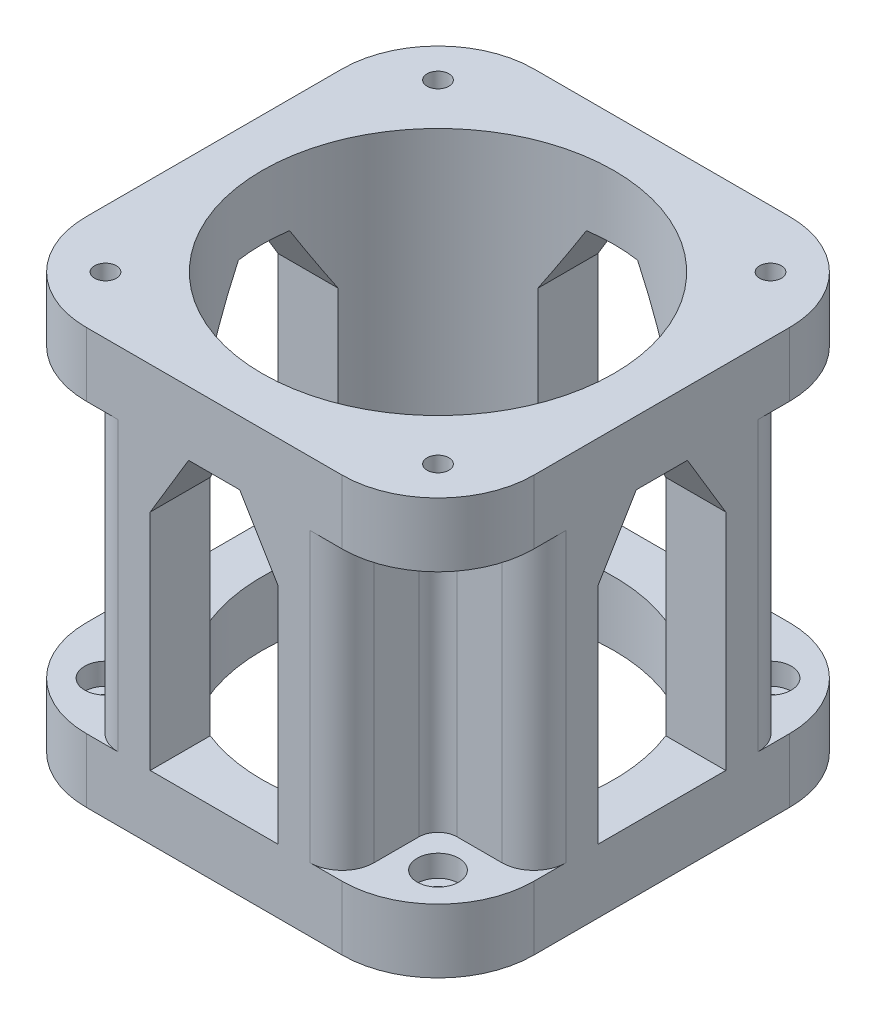
from build123d import *

# Parameters (mm, degrees)
SKETCH1_W                                           = 70
SKETCH1_H                                           = 70
BOSS_EXTRUDE1_DEPTH                                 = 65
FILLET1_R                                           = 15
SKETCH2_R                                           = 27.5
CUT_EXTRUDE1_DEPTH                                  = 65
CUT_EXTRUDE2_DEPTH                                  = 71
CUT_EXTRUDE3_DEPTH                                  = 71
CUT_EXTRUDE4_START                                  = -10
SKETCH10_W                                          = 15
SKETCH10_H                                          = 15
CUT_EXTRUDE4_DEPTH                                  = 45
CBORE_FOR_M3_HEX_SOCKET_HEAD_CAP_SCREW1_D           = 3.4
CBORE_FOR_M3_HEX_SOCKET_HEAD_CAP_SCREW1_DEPTH       = 10
CBORE_FOR_M3_HEX_SOCKET_HEAD_CAP_SCREW1_CBORE_D     = 6.5
CBORE_FOR_M3_HEX_SOCKET_HEAD_CAP_SCREW1_CBORE_DEPTH = 3.4
FILLET2_R                                           = 3
CBORE_FOR_M3_HEX_SOCKET_HEAD_CAP_SCREW2_D           = 3.4
CBORE_FOR_M3_HEX_SOCKET_HEAD_CAP_SCREW2_DEPTH       = 10
CBORE_FOR_M3_HEX_SOCKET_HEAD_CAP_SCREW2_CBORE_D     = 6.5
CBORE_FOR_M3_HEX_SOCKET_HEAD_CAP_SCREW2_CBORE_DEPTH = 3.4
FILLET3_R                                           = 5


with BuildPart() as part:
    # Sketch1 → Boss-Extrude1 (new body)
    with BuildSketch(Plane(origin=(0, 0, 0), x_dir=(1, 0, 0), z_dir=(0, 1, 0))):
        Rectangle(SKETCH1_W, SKETCH1_H)
    extrude(amount=BOSS_EXTRUDE1_DEPTH)

    # Fillet1
    fillet1_edges = [part.edges().sort_by_distance(p)[0] for p in [
        (-35, 32.5, -35),
        (35, 32.5, -35),
        (35, 32.5, 35),
        (-35, 32.5, 35),
    ]]
    fillet(fillet1_edges, radius=FILLET1_R)

    # Sketch2 → Cut-Extrude1 (cut)
    with BuildSketch(Plane(origin=(0, 65, 0), x_dir=(1, 0, 0), z_dir=(0, 1, 0))):
        Circle(SKETCH2_R)
    extrude(amount=-CUT_EXTRUDE1_DEPTH, mode=Mode.SUBTRACT)

    # Sketch3 → Cut-Extrude2 (cut, through all)
    with BuildSketch(Plane(origin=(0, 0, -35), x_dir=(-1, 0, 0), z_dir=(0, 0, -1))):
        Polygon((-10, 10), (-10, 45), (-4, 55), (4, 55), (10, 45), (10, 10), align=None)
    extrude(amount=-CUT_EXTRUDE2_DEPTH, mode=Mode.SUBTRACT)

    # Sketch4 → Cut-Extrude3 (cut, through all)
    with BuildSketch(Plane(origin=(35, 0, 0), x_dir=(0, 0, -1), z_dir=(1, 0, 0))):
        Polygon((-10, 10), (-10, 45), (-4, 55), (4, 55), (10, 45), (10, 10), align=None)
    extrude(amount=-CUT_EXTRUDE3_DEPTH, mode=Mode.SUBTRACT)

    # Sketch10 → Cut-Extrude4 (cut)
    with BuildSketch(Plane(origin=(0, 65, 0), x_dir=(1, 0, 0), z_dir=(0, 1, 0)).offset(CUT_EXTRUDE4_START)):
        with Locations((-27.5, 27.5)):
            Rectangle(SKETCH10_W, SKETCH10_H)
        with Locations((-27.5, -27.5)):
            Rectangle(SKETCH10_W, SKETCH10_H)
        with Locations((27.5, -27.5)):
            Rectangle(SKETCH10_W, SKETCH10_H)
        with Locations((27.5, 27.5)):
            Rectangle(SKETCH10_W, SKETCH10_H)
    extrude(amount=-CUT_EXTRUDE4_DEPTH, mode=Mode.SUBTRACT)

    # CBORE for M3 Hex Socket Head Cap Screw1
    with Locations(Plane(origin=(0, 55, 0), x_dir=(-1, 0, 0), z_dir=(0, -1, 0))):
        with Locations((26, -26), (-26, -26), (-26, 26), (26, 26)):
            CounterBoreHole(CBORE_FOR_M3_HEX_SOCKET_HEAD_CAP_SCREW1_D / 2, CBORE_FOR_M3_HEX_SOCKET_HEAD_CAP_SCREW1_CBORE_D / 2, CBORE_FOR_M3_HEX_SOCKET_HEAD_CAP_SCREW1_CBORE_DEPTH, depth=CBORE_FOR_M3_HEX_SOCKET_HEAD_CAP_SCREW1_DEPTH)

    # Fillet2
    fillet2_edges = [part.edges().sort_by_distance(p)[0] for p in [
        (20, 32.5, -20),
        (20, 32.5, 20),
        (-20, 32.5, 20),
        (-20, 32.5, -20),
    ]]
    fillet(fillet2_edges, radius=FILLET2_R)

    # CBORE for M3 Hex Socket Head Cap Screw2
    with Locations(Plane(origin=(0, 10, 0), x_dir=(1, 0, 0), z_dir=(0, 1, 0))):
        with Locations((26, -26), (26, 26), (-26, 26), (-26, -26)):
            CounterBoreHole(CBORE_FOR_M3_HEX_SOCKET_HEAD_CAP_SCREW2_D / 2, CBORE_FOR_M3_HEX_SOCKET_HEAD_CAP_SCREW2_CBORE_D / 2, CBORE_FOR_M3_HEX_SOCKET_HEAD_CAP_SCREW2_CBORE_DEPTH, depth=CBORE_FOR_M3_HEX_SOCKET_HEAD_CAP_SCREW2_DEPTH)

    # Fillet3
    fillet3_edges = [part.edges().sort_by_distance(p)[0] for p in [
        (35, 32.5, -20),
        (20, 32.5, -35),
        (35, 32.5, 20),
        (20, 32.5, 35),
        (-35, 32.5, 20),
        (-20, 32.5, 35),
        (-20, 32.5, -35),
        (-35, 32.5, -20),
    ]]
    fillet(fillet3_edges, radius=FILLET3_R)


solid = part.part
